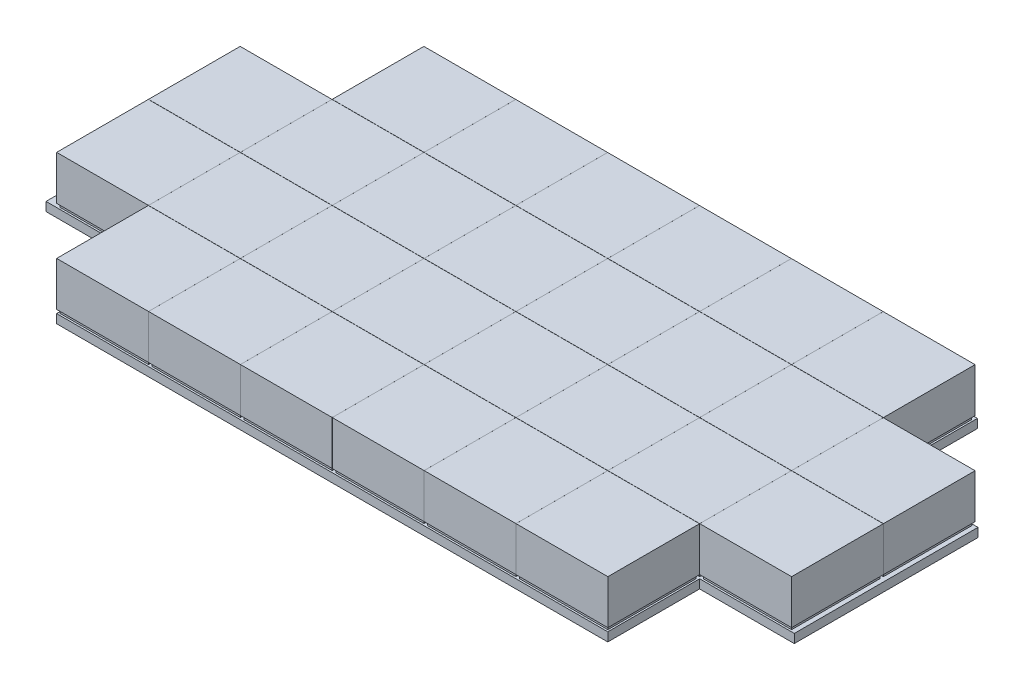
from build123d import *

# Parameters (mm, degrees)
SKETCH1_W                      = 480
SKETCH1_H                      = 270
BOSS_EXTRUDE1_DEPTH            = 5
SKETCH2_W                      = 50
SKETCH2_H                      = 50
BOSS_EXTRUDE3_DEPTH            = 2
LPATTERN1_COUNT                = 5
LPATTERN1_PITCH                = 52
SKETCH3_W                      = 52
SKETCH3_H                      = 51.9
BOSS_EXTRUDE8_DEPTH            = 25
LPATTERN5_COUNT                = 5
LPATTERN5_PITCH                = 52
LPATTERN6_COUNT                = 4
LPATTERN6_PITCH                = 52.01
LPATTERN6_COPY_1_SKETCH_W      = 50
LPATTERN6_COPY_1_SKETCH_H      = 50
LPATTERN6_COPY_1_DEPTH         = 2
LPATTERN6_COPY_2_SKETCH_W      = 50
LPATTERN6_COPY_2_SKETCH_H      = 50
LPATTERN6_COPY_2_DEPTH         = 2
LPATTERN6_COPY_3_SKETCH_W      = 50
LPATTERN6_COPY_3_SKETCH_H      = 50
LPATTERN6_COPY_3_DEPTH         = 2
LPATTERN6_COPY_4_SKETCH_W      = 50
LPATTERN6_COPY_4_SKETCH_H      = 50
LPATTERN6_COPY_4_DEPTH         = 2
LPATTERN6_COPY_5_SKETCH_W      = 50
LPATTERN6_COPY_5_SKETCH_H      = 50
LPATTERN6_COPY_5_DEPTH         = 2
LPATTERN6_COPY_6_SKETCH_W      = 50
LPATTERN6_COPY_6_SKETCH_H      = 50
LPATTERN6_COPY_6_DEPTH         = 2
LPATTERN6_COPY_7_SKETCH_W      = 50
LPATTERN6_COPY_7_SKETCH_H      = 50
LPATTERN6_COPY_7_DEPTH         = 2
LPATTERN6_COPY_8_SKETCH_W      = 50
LPATTERN6_COPY_8_SKETCH_H      = 50
LPATTERN6_COPY_8_DEPTH         = 2
LPATTERN6_COPY_9_SKETCH_W      = 50
LPATTERN6_COPY_9_SKETCH_H      = 50
LPATTERN6_COPY_9_DEPTH         = 2
LPATTERN6_COPY_10_SKETCH_W     = 50
LPATTERN6_COPY_10_SKETCH_H     = 50
LPATTERN6_COPY_10_DEPTH        = 2
LPATTERN6_COPY_11_SKETCH_W     = 50
LPATTERN6_COPY_11_SKETCH_H     = 50
LPATTERN6_COPY_11_DEPTH        = 2
LPATTERN6_COPY_12_SKETCH_W     = 50
LPATTERN6_COPY_12_SKETCH_H     = 50
LPATTERN6_COPY_12_DEPTH        = 2
LPATTERN6_COPY_13_SKETCH_W     = 52
LPATTERN6_COPY_13_SKETCH_H     = 51.9
LPATTERN6_COPY_13_DEPTH        = 25
LPATTERN6_COPY_14_SKETCH_W     = 52
LPATTERN6_COPY_14_SKETCH_H     = 51.9
LPATTERN6_COPY_14_DEPTH        = 25
LPATTERN6_COPY_15_SKETCH_W     = 52
LPATTERN6_COPY_15_SKETCH_H     = 51.9
LPATTERN6_COPY_15_DEPTH        = 25
LPATTERN6_COPY_16_SKETCH_W     = 52
LPATTERN6_COPY_16_SKETCH_H     = 51.9
LPATTERN6_COPY_16_DEPTH        = 25
LPATTERN6_COPY_17_SKETCH_W     = 52
LPATTERN6_COPY_17_SKETCH_H     = 51.9
LPATTERN6_COPY_17_DEPTH        = 25
LPATTERN6_COPY_18_SKETCH_W     = 52
LPATTERN6_COPY_18_SKETCH_H     = 51.9
LPATTERN6_COPY_18_DEPTH        = 25
LPATTERN6_COPY_19_SKETCH_W     = 52
LPATTERN6_COPY_19_SKETCH_H     = 51.9
LPATTERN6_COPY_19_DEPTH        = 25
LPATTERN6_COPY_20_SKETCH_W     = 52
LPATTERN6_COPY_20_SKETCH_H     = 51.9
LPATTERN6_COPY_20_DEPTH        = 25
LPATTERN6_COPY_21_SKETCH_W     = 52
LPATTERN6_COPY_21_SKETCH_H     = 51.9
LPATTERN6_COPY_21_DEPTH        = 25
LPATTERN6_COPY_22_SKETCH_W     = 52
LPATTERN6_COPY_22_SKETCH_H     = 51.9
LPATTERN6_COPY_22_DEPTH        = 25
LPATTERN6_COPY_23_SKETCH_W     = 52
LPATTERN6_COPY_23_SKETCH_H     = 51.9
LPATTERN6_COPY_23_DEPTH        = 25
LPATTERN6_COPY_24_SKETCH_W     = 52
LPATTERN6_COPY_24_SKETCH_H     = 51.9
LPATTERN6_COPY_24_DEPTH        = 25
LPATTERN6_COL_COUNT            = 5
LPATTERN6_COL_PITCH            = 52.01
LPATTERN6_COL_COPY_1_SKETCH_W  = 50
LPATTERN6_COL_COPY_1_SKETCH_H  = 50
LPATTERN6_COL_COPY_1_DEPTH     = 2
LPATTERN6_COL_COPY_2_SKETCH_W  = 50
LPATTERN6_COL_COPY_2_SKETCH_H  = 50
LPATTERN6_COL_COPY_2_DEPTH     = 2
LPATTERN6_COL_COPY_3_SKETCH_W  = 50
LPATTERN6_COL_COPY_3_SKETCH_H  = 50
LPATTERN6_COL_COPY_3_DEPTH     = 2
LPATTERN6_COL_COPY_4_SKETCH_W  = 50
LPATTERN6_COL_COPY_4_SKETCH_H  = 50
LPATTERN6_COL_COPY_4_DEPTH     = 2
LPATTERN6_COL_COPY_5_SKETCH_W  = 50
LPATTERN6_COL_COPY_5_SKETCH_H  = 50
LPATTERN6_COL_COPY_5_DEPTH     = 2
LPATTERN6_COL_COPY_6_SKETCH_W  = 50
LPATTERN6_COL_COPY_6_SKETCH_H  = 50
LPATTERN6_COL_COPY_6_DEPTH     = 2
LPATTERN6_COL_COPY_7_SKETCH_W  = 50
LPATTERN6_COL_COPY_7_SKETCH_H  = 50
LPATTERN6_COL_COPY_7_DEPTH     = 2
LPATTERN6_COL_COPY_8_SKETCH_W  = 50
LPATTERN6_COL_COPY_8_SKETCH_H  = 50
LPATTERN6_COL_COPY_8_DEPTH     = 2
LPATTERN6_COL_COPY_9_SKETCH_W  = 50
LPATTERN6_COL_COPY_9_SKETCH_H  = 50
LPATTERN6_COL_COPY_9_DEPTH     = 2
LPATTERN6_COL_COPY_10_SKETCH_W = 50
LPATTERN6_COL_COPY_10_SKETCH_H = 50
LPATTERN6_COL_COPY_10_DEPTH    = 2
LPATTERN6_COL_COPY_11_SKETCH_W = 50
LPATTERN6_COL_COPY_11_SKETCH_H = 50
LPATTERN6_COL_COPY_11_DEPTH    = 2
LPATTERN6_COL_COPY_12_SKETCH_W = 50
LPATTERN6_COL_COPY_12_SKETCH_H = 50
LPATTERN6_COL_COPY_12_DEPTH    = 2
LPATTERN6_COL_COPY_13_SKETCH_W = 50
LPATTERN6_COL_COPY_13_SKETCH_H = 50
LPATTERN6_COL_COPY_13_DEPTH    = 2
LPATTERN6_COL_COPY_14_SKETCH_W = 50
LPATTERN6_COL_COPY_14_SKETCH_H = 50
LPATTERN6_COL_COPY_14_DEPTH    = 2
LPATTERN6_COL_COPY_15_SKETCH_W = 50
LPATTERN6_COL_COPY_15_SKETCH_H = 50
LPATTERN6_COL_COPY_15_DEPTH    = 2
LPATTERN6_COL_COPY_16_SKETCH_W = 50
LPATTERN6_COL_COPY_16_SKETCH_H = 50
LPATTERN6_COL_COPY_16_DEPTH    = 2
LPATTERN6_COL_COPY_17_SKETCH_W = 52
LPATTERN6_COL_COPY_17_SKETCH_H = 51.9
LPATTERN6_COL_COPY_17_DEPTH    = 25
LPATTERN6_COL_COPY_18_SKETCH_W = 52
LPATTERN6_COL_COPY_18_SKETCH_H = 51.9
LPATTERN6_COL_COPY_18_DEPTH    = 25
LPATTERN6_COL_COPY_19_SKETCH_W = 52
LPATTERN6_COL_COPY_19_SKETCH_H = 51.9
LPATTERN6_COL_COPY_19_DEPTH    = 25
LPATTERN6_COL_COPY_20_SKETCH_W = 52
LPATTERN6_COL_COPY_20_SKETCH_H = 51.9
LPATTERN6_COL_COPY_20_DEPTH    = 25
LPATTERN6_COL_COPY_21_SKETCH_W = 52
LPATTERN6_COL_COPY_21_SKETCH_H = 51.9
LPATTERN6_COL_COPY_21_DEPTH    = 25
LPATTERN6_COL_COPY_22_SKETCH_W = 52
LPATTERN6_COL_COPY_22_SKETCH_H = 51.9
LPATTERN6_COL_COPY_22_DEPTH    = 25
LPATTERN6_COL_COPY_23_SKETCH_W = 52
LPATTERN6_COL_COPY_23_SKETCH_H = 51.9
LPATTERN6_COL_COPY_23_DEPTH    = 25
LPATTERN6_COL_COPY_24_SKETCH_W = 52
LPATTERN6_COL_COPY_24_SKETCH_H = 51.9
LPATTERN6_COL_COPY_24_DEPTH    = 25
LPATTERN6_COL_COPY_25_SKETCH_W = 52
LPATTERN6_COL_COPY_25_SKETCH_H = 51.9
LPATTERN6_COL_COPY_25_DEPTH    = 25
LPATTERN6_COL_COPY_26_SKETCH_W = 52
LPATTERN6_COL_COPY_26_SKETCH_H = 51.9
LPATTERN6_COL_COPY_26_DEPTH    = 25
LPATTERN6_COL_COPY_27_SKETCH_W = 52
LPATTERN6_COL_COPY_27_SKETCH_H = 51.9
LPATTERN6_COL_COPY_27_DEPTH    = 25
LPATTERN6_COL_COPY_28_SKETCH_W = 52
LPATTERN6_COL_COPY_28_SKETCH_H = 51.9
LPATTERN6_COL_COPY_28_DEPTH    = 25
LPATTERN6_COL_COPY_29_SKETCH_W = 52
LPATTERN6_COL_COPY_29_SKETCH_H = 51.9
LPATTERN6_COL_COPY_29_DEPTH    = 25
LPATTERN6_COL_COPY_30_SKETCH_W = 52
LPATTERN6_COL_COPY_30_SKETCH_H = 51.9
LPATTERN6_COL_COPY_30_DEPTH    = 25
LPATTERN6_COL_COPY_31_SKETCH_W = 52
LPATTERN6_COL_COPY_31_SKETCH_H = 51.9
LPATTERN6_COL_COPY_31_DEPTH    = 25
LPATTERN6_COL_COPY_32_SKETCH_W = 52
LPATTERN6_COL_COPY_32_SKETCH_H = 51.9
LPATTERN6_COL_COPY_32_DEPTH    = 25
SKETCH4_W                      = 109.974703244
SKETCH4_H                      = 58.050900686
SKETCH4_W_2                    = 57.965516085
SKETCH4_H_2                    = 107.940678317
CUT_EXTRUDE1_DEPTH             = 28
CUT_EXTRUDE1_DEPTH_BACK        = 6
SKETCH5_W                      = 312.059780671
SKETCH5_H                      = 55.947915886
SKETCH5_W_2                    = 56.382615361
SKETCH5_H_2                    = 104.008420997
SKETCH5_H_3                    = 4.790225888
CUT_EXTRUDE2_DEPTH             = 28
CUT_EXTRUDE2_DEPTH_BACK        = 6


with BuildPart() as part:
    # Sketch1 → Boss-Extrude1 (new body)
    with BuildSketch(Plane(origin=(0, 0, 0), x_dir=(1, 0, 0), z_dir=(0, 1, 0))):
        Rectangle(SKETCH1_W, SKETCH1_H)
    extrude(amount=BOSS_EXTRUDE1_DEPTH)

    # Sketch2 → Boss-Extrude3 (add)
    with BuildSketch(Plane(origin=(0, 5, 0), x_dir=(1, 0, 0), z_dir=(0, 1, 0))):
        with Locations((0, -105)):
            Rectangle(SKETCH2_W, SKETCH2_H)
    boss_extrude3 = extrude(amount=BOSS_EXTRUDE3_DEPTH)

    # LPattern1: Boss-Extrude3 ×5
    with Locations(*[(0, 0, -i * LPATTERN1_PITCH) for i in range(1, LPATTERN1_COUNT)]):
        add(boss_extrude3)

    # Sketch3 → Boss-Extrude8 (add)
    with BuildSketch(Plane(origin=(0, 7, 0), x_dir=(1, 0, 0), z_dir=(0, 1, 0))):
        with Locations((0, -105.05)):
            Rectangle(SKETCH3_W, SKETCH3_H)
    boss_extrude8 = extrude(amount=BOSS_EXTRUDE8_DEPTH)

    # LPattern5: Boss-Extrude8 ×5
    with Locations(*[(0, 0, -i * LPATTERN5_PITCH) for i in range(1, LPATTERN5_COUNT)]):
        add(boss_extrude8)

    # LPattern6: Boss-Extrude3, Boss-Extrude8 ×4
    with Locations(*[(i * LPATTERN6_PITCH, 0, 0) for i in range(1, LPATTERN6_COUNT)]):
        add(boss_extrude3)
        add(boss_extrude8)

    # LPattern6 copy 1 sketch → LPattern6 copy 1 (add)
    with BuildSketch(Plane(origin=(52.01, 5, -52), x_dir=(1, 0, 0), z_dir=(0, 1, 0))):
        with Locations((0, -105)):
            Rectangle(LPATTERN6_COPY_1_SKETCH_W, LPATTERN6_COPY_1_SKETCH_H)
    extrude(amount=LPATTERN6_COPY_1_DEPTH)

    # LPattern6 copy 2 sketch → LPattern6 copy 2 (add)
    with BuildSketch(Plane(origin=(104.02, 5, -52), x_dir=(1, 0, 0), z_dir=(0, 1, 0))):
        with Locations((0, -105)):
            Rectangle(LPATTERN6_COPY_2_SKETCH_W, LPATTERN6_COPY_2_SKETCH_H)
    extrude(amount=LPATTERN6_COPY_2_DEPTH)

    # LPattern6 copy 3 sketch → LPattern6 copy 3 (add)
    with BuildSketch(Plane(origin=(156.03, 5, -52), x_dir=(1, 0, 0), z_dir=(0, 1, 0))):
        with Locations((0, -105)):
            Rectangle(LPATTERN6_COPY_3_SKETCH_W, LPATTERN6_COPY_3_SKETCH_H)
    extrude(amount=LPATTERN6_COPY_3_DEPTH)

    # LPattern6 copy 4 sketch → LPattern6 copy 4 (add)
    with BuildSketch(Plane(origin=(52.01, 5, -104), x_dir=(1, 0, 0), z_dir=(0, 1, 0))):
        with Locations((0, -105)):
            Rectangle(LPATTERN6_COPY_4_SKETCH_W, LPATTERN6_COPY_4_SKETCH_H)
    extrude(amount=LPATTERN6_COPY_4_DEPTH)

    # LPattern6 copy 5 sketch → LPattern6 copy 5 (add)
    with BuildSketch(Plane(origin=(104.02, 5, -104), x_dir=(1, 0, 0), z_dir=(0, 1, 0))):
        with Locations((0, -105)):
            Rectangle(LPATTERN6_COPY_5_SKETCH_W, LPATTERN6_COPY_5_SKETCH_H)
    extrude(amount=LPATTERN6_COPY_5_DEPTH)

    # LPattern6 copy 6 sketch → LPattern6 copy 6 (add)
    with BuildSketch(Plane(origin=(156.03, 5, -104), x_dir=(1, 0, 0), z_dir=(0, 1, 0))):
        with Locations((0, -105)):
            Rectangle(LPATTERN6_COPY_6_SKETCH_W, LPATTERN6_COPY_6_SKETCH_H)
    extrude(amount=LPATTERN6_COPY_6_DEPTH)

    # LPattern6 copy 7 sketch → LPattern6 copy 7 (add)
    with BuildSketch(Plane(origin=(52.01, 5, -156), x_dir=(1, 0, 0), z_dir=(0, 1, 0))):
        with Locations((0, -105)):
            Rectangle(LPATTERN6_COPY_7_SKETCH_W, LPATTERN6_COPY_7_SKETCH_H)
    extrude(amount=LPATTERN6_COPY_7_DEPTH)

    # LPattern6 copy 8 sketch → LPattern6 copy 8 (add)
    with BuildSketch(Plane(origin=(104.02, 5, -156), x_dir=(1, 0, 0), z_dir=(0, 1, 0))):
        with Locations((0, -105)):
            Rectangle(LPATTERN6_COPY_8_SKETCH_W, LPATTERN6_COPY_8_SKETCH_H)
    extrude(amount=LPATTERN6_COPY_8_DEPTH)

    # LPattern6 copy 9 sketch → LPattern6 copy 9 (add)
    with BuildSketch(Plane(origin=(156.03, 5, -156), x_dir=(1, 0, 0), z_dir=(0, 1, 0))):
        with Locations((0, -105)):
            Rectangle(LPATTERN6_COPY_9_SKETCH_W, LPATTERN6_COPY_9_SKETCH_H)
    extrude(amount=LPATTERN6_COPY_9_DEPTH)

    # LPattern6 copy 10 sketch → LPattern6 copy 10 (add)
    with BuildSketch(Plane(origin=(52.01, 5, -208), x_dir=(1, 0, 0), z_dir=(0, 1, 0))):
        with Locations((0, -105)):
            Rectangle(LPATTERN6_COPY_10_SKETCH_W, LPATTERN6_COPY_10_SKETCH_H)
    extrude(amount=LPATTERN6_COPY_10_DEPTH)

    # LPattern6 copy 11 sketch → LPattern6 copy 11 (add)
    with BuildSketch(Plane(origin=(104.02, 5, -208), x_dir=(1, 0, 0), z_dir=(0, 1, 0))):
        with Locations((0, -105)):
            Rectangle(LPATTERN6_COPY_11_SKETCH_W, LPATTERN6_COPY_11_SKETCH_H)
    extrude(amount=LPATTERN6_COPY_11_DEPTH)

    # LPattern6 copy 12 sketch → LPattern6 copy 12 (add)
    with BuildSketch(Plane(origin=(156.03, 5, -208), x_dir=(1, 0, 0), z_dir=(0, 1, 0))):
        with Locations((0, -105)):
            Rectangle(LPATTERN6_COPY_12_SKETCH_W, LPATTERN6_COPY_12_SKETCH_H)
    extrude(amount=LPATTERN6_COPY_12_DEPTH)

    # LPattern6 copy 13 sketch → LPattern6 copy 13 (add)
    with BuildSketch(Plane(origin=(52.01, 7, -52), x_dir=(1, 0, 0), z_dir=(0, 1, 0))):
        with Locations((0, -105.05)):
            Rectangle(LPATTERN6_COPY_13_SKETCH_W, LPATTERN6_COPY_13_SKETCH_H)
    extrude(amount=LPATTERN6_COPY_13_DEPTH)

    # LPattern6 copy 14 sketch → LPattern6 copy 14 (add)
    with BuildSketch(Plane(origin=(104.02, 7, -52), x_dir=(1, 0, 0), z_dir=(0, 1, 0))):
        with Locations((0, -105.05)):
            Rectangle(LPATTERN6_COPY_14_SKETCH_W, LPATTERN6_COPY_14_SKETCH_H)
    extrude(amount=LPATTERN6_COPY_14_DEPTH)

    # LPattern6 copy 15 sketch → LPattern6 copy 15 (add)
    with BuildSketch(Plane(origin=(156.03, 7, -52), x_dir=(1, 0, 0), z_dir=(0, 1, 0))):
        with Locations((0, -105.05)):
            Rectangle(LPATTERN6_COPY_15_SKETCH_W, LPATTERN6_COPY_15_SKETCH_H)
    extrude(amount=LPATTERN6_COPY_15_DEPTH)

    # LPattern6 copy 16 sketch → LPattern6 copy 16 (add)
    with BuildSketch(Plane(origin=(52.01, 7, -104), x_dir=(1, 0, 0), z_dir=(0, 1, 0))):
        with Locations((0, -105.05)):
            Rectangle(LPATTERN6_COPY_16_SKETCH_W, LPATTERN6_COPY_16_SKETCH_H)
    extrude(amount=LPATTERN6_COPY_16_DEPTH)

    # LPattern6 copy 17 sketch → LPattern6 copy 17 (add)
    with BuildSketch(Plane(origin=(104.02, 7, -104), x_dir=(1, 0, 0), z_dir=(0, 1, 0))):
        with Locations((0, -105.05)):
            Rectangle(LPATTERN6_COPY_17_SKETCH_W, LPATTERN6_COPY_17_SKETCH_H)
    extrude(amount=LPATTERN6_COPY_17_DEPTH)

    # LPattern6 copy 18 sketch → LPattern6 copy 18 (add)
    with BuildSketch(Plane(origin=(156.03, 7, -104), x_dir=(1, 0, 0), z_dir=(0, 1, 0))):
        with Locations((0, -105.05)):
            Rectangle(LPATTERN6_COPY_18_SKETCH_W, LPATTERN6_COPY_18_SKETCH_H)
    extrude(amount=LPATTERN6_COPY_18_DEPTH)

    # LPattern6 copy 19 sketch → LPattern6 copy 19 (add)
    with BuildSketch(Plane(origin=(52.01, 7, -156), x_dir=(1, 0, 0), z_dir=(0, 1, 0))):
        with Locations((0, -105.05)):
            Rectangle(LPATTERN6_COPY_19_SKETCH_W, LPATTERN6_COPY_19_SKETCH_H)
    extrude(amount=LPATTERN6_COPY_19_DEPTH)

    # LPattern6 copy 20 sketch → LPattern6 copy 20 (add)
    with BuildSketch(Plane(origin=(104.02, 7, -156), x_dir=(1, 0, 0), z_dir=(0, 1, 0))):
        with Locations((0, -105.05)):
            Rectangle(LPATTERN6_COPY_20_SKETCH_W, LPATTERN6_COPY_20_SKETCH_H)
    extrude(amount=LPATTERN6_COPY_20_DEPTH)

    # LPattern6 copy 21 sketch → LPattern6 copy 21 (add)
    with BuildSketch(Plane(origin=(156.03, 7, -156), x_dir=(1, 0, 0), z_dir=(0, 1, 0))):
        with Locations((0, -105.05)):
            Rectangle(LPATTERN6_COPY_21_SKETCH_W, LPATTERN6_COPY_21_SKETCH_H)
    extrude(amount=LPATTERN6_COPY_21_DEPTH)

    # LPattern6 copy 22 sketch → LPattern6 copy 22 (add)
    with BuildSketch(Plane(origin=(52.01, 7, -208), x_dir=(1, 0, 0), z_dir=(0, 1, 0))):
        with Locations((0, -105.05)):
            Rectangle(LPATTERN6_COPY_22_SKETCH_W, LPATTERN6_COPY_22_SKETCH_H)
    extrude(amount=LPATTERN6_COPY_22_DEPTH)

    # LPattern6 copy 23 sketch → LPattern6 copy 23 (add)
    with BuildSketch(Plane(origin=(104.02, 7, -208), x_dir=(1, 0, 0), z_dir=(0, 1, 0))):
        with Locations((0, -105.05)):
            Rectangle(LPATTERN6_COPY_23_SKETCH_W, LPATTERN6_COPY_23_SKETCH_H)
    extrude(amount=LPATTERN6_COPY_23_DEPTH)

    # LPattern6 copy 24 sketch → LPattern6 copy 24 (add)
    with BuildSketch(Plane(origin=(156.03, 7, -208), x_dir=(1, 0, 0), z_dir=(0, 1, 0))):
        with Locations((0, -105.05)):
            Rectangle(LPATTERN6_COPY_24_SKETCH_W, LPATTERN6_COPY_24_SKETCH_H)
    extrude(amount=LPATTERN6_COPY_24_DEPTH)

    # LPattern6 col: Boss-Extrude3, Boss-Extrude8 ×5
    with Locations(*[(-i * LPATTERN6_COL_PITCH, 0, 0) for i in range(1, LPATTERN6_COL_COUNT)]):
        add(boss_extrude3)
        add(boss_extrude8)

    # LPattern6 col copy 1 sketch → LPattern6 col copy 1 (add)
    with BuildSketch(Plane(origin=(-52.01, 5, -52), x_dir=(1, 0, 0), z_dir=(0, 1, 0))):
        with Locations((0, -105)):
            Rectangle(LPATTERN6_COL_COPY_1_SKETCH_W, LPATTERN6_COL_COPY_1_SKETCH_H)
    extrude(amount=LPATTERN6_COL_COPY_1_DEPTH)

    # LPattern6 col copy 2 sketch → LPattern6 col copy 2 (add)
    with BuildSketch(Plane(origin=(-104.02, 5, -52), x_dir=(1, 0, 0), z_dir=(0, 1, 0))):
        with Locations((0, -105)):
            Rectangle(LPATTERN6_COL_COPY_2_SKETCH_W, LPATTERN6_COL_COPY_2_SKETCH_H)
    extrude(amount=LPATTERN6_COL_COPY_2_DEPTH)

    # LPattern6 col copy 3 sketch → LPattern6 col copy 3 (add)
    with BuildSketch(Plane(origin=(-156.03, 5, -52), x_dir=(1, 0, 0), z_dir=(0, 1, 0))):
        with Locations((0, -105)):
            Rectangle(LPATTERN6_COL_COPY_3_SKETCH_W, LPATTERN6_COL_COPY_3_SKETCH_H)
    extrude(amount=LPATTERN6_COL_COPY_3_DEPTH)

    # LPattern6 col copy 4 sketch → LPattern6 col copy 4 (add)
    with BuildSketch(Plane(origin=(-208.04, 5, -52), x_dir=(1, 0, 0), z_dir=(0, 1, 0))):
        with Locations((0, -105)):
            Rectangle(LPATTERN6_COL_COPY_4_SKETCH_W, LPATTERN6_COL_COPY_4_SKETCH_H)
    extrude(amount=LPATTERN6_COL_COPY_4_DEPTH)

    # LPattern6 col copy 5 sketch → LPattern6 col copy 5 (add)
    with BuildSketch(Plane(origin=(-52.01, 5, -104), x_dir=(1, 0, 0), z_dir=(0, 1, 0))):
        with Locations((0, -105)):
            Rectangle(LPATTERN6_COL_COPY_5_SKETCH_W, LPATTERN6_COL_COPY_5_SKETCH_H)
    extrude(amount=LPATTERN6_COL_COPY_5_DEPTH)

    # LPattern6 col copy 6 sketch → LPattern6 col copy 6 (add)
    with BuildSketch(Plane(origin=(-104.02, 5, -104), x_dir=(1, 0, 0), z_dir=(0, 1, 0))):
        with Locations((0, -105)):
            Rectangle(LPATTERN6_COL_COPY_6_SKETCH_W, LPATTERN6_COL_COPY_6_SKETCH_H)
    extrude(amount=LPATTERN6_COL_COPY_6_DEPTH)

    # LPattern6 col copy 7 sketch → LPattern6 col copy 7 (add)
    with BuildSketch(Plane(origin=(-156.03, 5, -104), x_dir=(1, 0, 0), z_dir=(0, 1, 0))):
        with Locations((0, -105)):
            Rectangle(LPATTERN6_COL_COPY_7_SKETCH_W, LPATTERN6_COL_COPY_7_SKETCH_H)
    extrude(amount=LPATTERN6_COL_COPY_7_DEPTH)

    # LPattern6 col copy 8 sketch → LPattern6 col copy 8 (add)
    with BuildSketch(Plane(origin=(-208.04, 5, -104), x_dir=(1, 0, 0), z_dir=(0, 1, 0))):
        with Locations((0, -105)):
            Rectangle(LPATTERN6_COL_COPY_8_SKETCH_W, LPATTERN6_COL_COPY_8_SKETCH_H)
    extrude(amount=LPATTERN6_COL_COPY_8_DEPTH)

    # LPattern6 col copy 9 sketch → LPattern6 col copy 9 (add)
    with BuildSketch(Plane(origin=(-52.01, 5, -156), x_dir=(1, 0, 0), z_dir=(0, 1, 0))):
        with Locations((0, -105)):
            Rectangle(LPATTERN6_COL_COPY_9_SKETCH_W, LPATTERN6_COL_COPY_9_SKETCH_H)
    extrude(amount=LPATTERN6_COL_COPY_9_DEPTH)

    # LPattern6 col copy 10 sketch → LPattern6 col copy 10 (add)
    with BuildSketch(Plane(origin=(-104.02, 5, -156), x_dir=(1, 0, 0), z_dir=(0, 1, 0))):
        with Locations((0, -105)):
            Rectangle(LPATTERN6_COL_COPY_10_SKETCH_W, LPATTERN6_COL_COPY_10_SKETCH_H)
    extrude(amount=LPATTERN6_COL_COPY_10_DEPTH)

    # LPattern6 col copy 11 sketch → LPattern6 col copy 11 (add)
    with BuildSketch(Plane(origin=(-156.03, 5, -156), x_dir=(1, 0, 0), z_dir=(0, 1, 0))):
        with Locations((0, -105)):
            Rectangle(LPATTERN6_COL_COPY_11_SKETCH_W, LPATTERN6_COL_COPY_11_SKETCH_H)
    extrude(amount=LPATTERN6_COL_COPY_11_DEPTH)

    # LPattern6 col copy 12 sketch → LPattern6 col copy 12 (add)
    with BuildSketch(Plane(origin=(-208.04, 5, -156), x_dir=(1, 0, 0), z_dir=(0, 1, 0))):
        with Locations((0, -105)):
            Rectangle(LPATTERN6_COL_COPY_12_SKETCH_W, LPATTERN6_COL_COPY_12_SKETCH_H)
    extrude(amount=LPATTERN6_COL_COPY_12_DEPTH)

    # LPattern6 col copy 13 sketch → LPattern6 col copy 13 (add)
    with BuildSketch(Plane(origin=(-52.01, 5, -208), x_dir=(1, 0, 0), z_dir=(0, 1, 0))):
        with Locations((0, -105)):
            Rectangle(LPATTERN6_COL_COPY_13_SKETCH_W, LPATTERN6_COL_COPY_13_SKETCH_H)
    extrude(amount=LPATTERN6_COL_COPY_13_DEPTH)

    # LPattern6 col copy 14 sketch → LPattern6 col copy 14 (add)
    with BuildSketch(Plane(origin=(-104.02, 5, -208), x_dir=(1, 0, 0), z_dir=(0, 1, 0))):
        with Locations((0, -105)):
            Rectangle(LPATTERN6_COL_COPY_14_SKETCH_W, LPATTERN6_COL_COPY_14_SKETCH_H)
    extrude(amount=LPATTERN6_COL_COPY_14_DEPTH)

    # LPattern6 col copy 15 sketch → LPattern6 col copy 15 (add)
    with BuildSketch(Plane(origin=(-156.03, 5, -208), x_dir=(1, 0, 0), z_dir=(0, 1, 0))):
        with Locations((0, -105)):
            Rectangle(LPATTERN6_COL_COPY_15_SKETCH_W, LPATTERN6_COL_COPY_15_SKETCH_H)
    extrude(amount=LPATTERN6_COL_COPY_15_DEPTH)

    # LPattern6 col copy 16 sketch → LPattern6 col copy 16 (add)
    with BuildSketch(Plane(origin=(-208.04, 5, -208), x_dir=(1, 0, 0), z_dir=(0, 1, 0))):
        with Locations((0, -105)):
            Rectangle(LPATTERN6_COL_COPY_16_SKETCH_W, LPATTERN6_COL_COPY_16_SKETCH_H)
    extrude(amount=LPATTERN6_COL_COPY_16_DEPTH)

    # LPattern6 col copy 17 sketch → LPattern6 col copy 17 (add)
    with BuildSketch(Plane(origin=(-52.01, 7, -52), x_dir=(1, 0, 0), z_dir=(0, 1, 0))):
        with Locations((0, -105.05)):
            Rectangle(LPATTERN6_COL_COPY_17_SKETCH_W, LPATTERN6_COL_COPY_17_SKETCH_H)
    extrude(amount=LPATTERN6_COL_COPY_17_DEPTH)

    # LPattern6 col copy 18 sketch → LPattern6 col copy 18 (add)
    with BuildSketch(Plane(origin=(-104.02, 7, -52), x_dir=(1, 0, 0), z_dir=(0, 1, 0))):
        with Locations((0, -105.05)):
            Rectangle(LPATTERN6_COL_COPY_18_SKETCH_W, LPATTERN6_COL_COPY_18_SKETCH_H)
    extrude(amount=LPATTERN6_COL_COPY_18_DEPTH)

    # LPattern6 col copy 19 sketch → LPattern6 col copy 19 (add)
    with BuildSketch(Plane(origin=(-156.03, 7, -52), x_dir=(1, 0, 0), z_dir=(0, 1, 0))):
        with Locations((0, -105.05)):
            Rectangle(LPATTERN6_COL_COPY_19_SKETCH_W, LPATTERN6_COL_COPY_19_SKETCH_H)
    extrude(amount=LPATTERN6_COL_COPY_19_DEPTH)

    # LPattern6 col copy 20 sketch → LPattern6 col copy 20 (add)
    with BuildSketch(Plane(origin=(-208.04, 7, -52), x_dir=(1, 0, 0), z_dir=(0, 1, 0))):
        with Locations((0, -105.05)):
            Rectangle(LPATTERN6_COL_COPY_20_SKETCH_W, LPATTERN6_COL_COPY_20_SKETCH_H)
    extrude(amount=LPATTERN6_COL_COPY_20_DEPTH)

    # LPattern6 col copy 21 sketch → LPattern6 col copy 21 (add)
    with BuildSketch(Plane(origin=(-52.01, 7, -104), x_dir=(1, 0, 0), z_dir=(0, 1, 0))):
        with Locations((0, -105.05)):
            Rectangle(LPATTERN6_COL_COPY_21_SKETCH_W, LPATTERN6_COL_COPY_21_SKETCH_H)
    extrude(amount=LPATTERN6_COL_COPY_21_DEPTH)

    # LPattern6 col copy 22 sketch → LPattern6 col copy 22 (add)
    with BuildSketch(Plane(origin=(-104.02, 7, -104), x_dir=(1, 0, 0), z_dir=(0, 1, 0))):
        with Locations((0, -105.05)):
            Rectangle(LPATTERN6_COL_COPY_22_SKETCH_W, LPATTERN6_COL_COPY_22_SKETCH_H)
    extrude(amount=LPATTERN6_COL_COPY_22_DEPTH)

    # LPattern6 col copy 23 sketch → LPattern6 col copy 23 (add)
    with BuildSketch(Plane(origin=(-156.03, 7, -104), x_dir=(1, 0, 0), z_dir=(0, 1, 0))):
        with Locations((0, -105.05)):
            Rectangle(LPATTERN6_COL_COPY_23_SKETCH_W, LPATTERN6_COL_COPY_23_SKETCH_H)
    extrude(amount=LPATTERN6_COL_COPY_23_DEPTH)

    # LPattern6 col copy 24 sketch → LPattern6 col copy 24 (add)
    with BuildSketch(Plane(origin=(-208.04, 7, -104), x_dir=(1, 0, 0), z_dir=(0, 1, 0))):
        with Locations((0, -105.05)):
            Rectangle(LPATTERN6_COL_COPY_24_SKETCH_W, LPATTERN6_COL_COPY_24_SKETCH_H)
    extrude(amount=LPATTERN6_COL_COPY_24_DEPTH)

    # LPattern6 col copy 25 sketch → LPattern6 col copy 25 (add)
    with BuildSketch(Plane(origin=(-52.01, 7, -156), x_dir=(1, 0, 0), z_dir=(0, 1, 0))):
        with Locations((0, -105.05)):
            Rectangle(LPATTERN6_COL_COPY_25_SKETCH_W, LPATTERN6_COL_COPY_25_SKETCH_H)
    extrude(amount=LPATTERN6_COL_COPY_25_DEPTH)

    # LPattern6 col copy 26 sketch → LPattern6 col copy 26 (add)
    with BuildSketch(Plane(origin=(-104.02, 7, -156), x_dir=(1, 0, 0), z_dir=(0, 1, 0))):
        with Locations((0, -105.05)):
            Rectangle(LPATTERN6_COL_COPY_26_SKETCH_W, LPATTERN6_COL_COPY_26_SKETCH_H)
    extrude(amount=LPATTERN6_COL_COPY_26_DEPTH)

    # LPattern6 col copy 27 sketch → LPattern6 col copy 27 (add)
    with BuildSketch(Plane(origin=(-156.03, 7, -156), x_dir=(1, 0, 0), z_dir=(0, 1, 0))):
        with Locations((0, -105.05)):
            Rectangle(LPATTERN6_COL_COPY_27_SKETCH_W, LPATTERN6_COL_COPY_27_SKETCH_H)
    extrude(amount=LPATTERN6_COL_COPY_27_DEPTH)

    # LPattern6 col copy 28 sketch → LPattern6 col copy 28 (add)
    with BuildSketch(Plane(origin=(-208.04, 7, -156), x_dir=(1, 0, 0), z_dir=(0, 1, 0))):
        with Locations((0, -105.05)):
            Rectangle(LPATTERN6_COL_COPY_28_SKETCH_W, LPATTERN6_COL_COPY_28_SKETCH_H)
    extrude(amount=LPATTERN6_COL_COPY_28_DEPTH)

    # LPattern6 col copy 29 sketch → LPattern6 col copy 29 (add)
    with BuildSketch(Plane(origin=(-52.01, 7, -208), x_dir=(1, 0, 0), z_dir=(0, 1, 0))):
        with Locations((0, -105.05)):
            Rectangle(LPATTERN6_COL_COPY_29_SKETCH_W, LPATTERN6_COL_COPY_29_SKETCH_H)
    extrude(amount=LPATTERN6_COL_COPY_29_DEPTH)

    # LPattern6 col copy 30 sketch → LPattern6 col copy 30 (add)
    with BuildSketch(Plane(origin=(-104.02, 7, -208), x_dir=(1, 0, 0), z_dir=(0, 1, 0))):
        with Locations((0, -105.05)):
            Rectangle(LPATTERN6_COL_COPY_30_SKETCH_W, LPATTERN6_COL_COPY_30_SKETCH_H)
    extrude(amount=LPATTERN6_COL_COPY_30_DEPTH)

    # LPattern6 col copy 31 sketch → LPattern6 col copy 31 (add)
    with BuildSketch(Plane(origin=(-156.03, 7, -208), x_dir=(1, 0, 0), z_dir=(0, 1, 0))):
        with Locations((0, -105.05)):
            Rectangle(LPATTERN6_COL_COPY_31_SKETCH_W, LPATTERN6_COL_COPY_31_SKETCH_H)
    extrude(amount=LPATTERN6_COL_COPY_31_DEPTH)

    # LPattern6 col copy 32 sketch → LPattern6 col copy 32 (add)
    with BuildSketch(Plane(origin=(-208.04, 7, -208), x_dir=(1, 0, 0), z_dir=(0, 1, 0))):
        with Locations((0, -105.05)):
            Rectangle(LPATTERN6_COL_COPY_32_SKETCH_W, LPATTERN6_COL_COPY_32_SKETCH_H)
    extrude(amount=LPATTERN6_COL_COPY_32_DEPTH)

    # Sketch4 → Cut-Extrude1 (cut, two sides)
    with BuildSketch(Plane(origin=(0, 5, 0), x_dir=(1, 0, 0), z_dir=(0, 1, 0))) as cut_extrude1_sk:
        with Locations((185.012648378, 105.974549657)):
            Rectangle(SKETCH4_W, SKETCH4_H)
        with Locations((-211.017241958, 105.974549657)):
            Rectangle(SKETCH4_W_2, SKETCH4_H)
        with Locations((-211.017241958, -81.029660842)):
            Rectangle(SKETCH4_W_2, SKETCH4_H_2)
        with Locations((185.012648378, -81.029660842)):
            Rectangle(SKETCH4_W, SKETCH4_H_2)
    extrude(amount=CUT_EXTRUDE1_DEPTH, mode=Mode.SUBTRACT)
    extrude(cut_extrude1_sk.sketch, amount=-CUT_EXTRUDE1_DEPTH_BACK, mode=Mode.SUBTRACT)

    # Sketch5 → Cut-Extrude2 (cut, two sides)
    with BuildSketch(Plane(origin=(0, 5, 0), x_dir=(1, 0, 0), z_dir=(0, 1, 0))) as cut_extrude2_sk:
        with Locations((-26.004593579, -107.026042057)):
            Rectangle(SKETCH5_W, SKETCH5_H)
        with Locations((211.80869232, 24.944888816)):
            Rectangle(SKETCH5_W_2, SKETCH5_H_2)
        with Locations((-26.004593579, 132.604887056)):
            Rectangle(SKETCH5_W, SKETCH5_H_3)
    extrude(amount=CUT_EXTRUDE2_DEPTH, mode=Mode.SUBTRACT)
    extrude(cut_extrude2_sk.sketch, amount=-CUT_EXTRUDE2_DEPTH_BACK, mode=Mode.SUBTRACT)


solid = part.part
